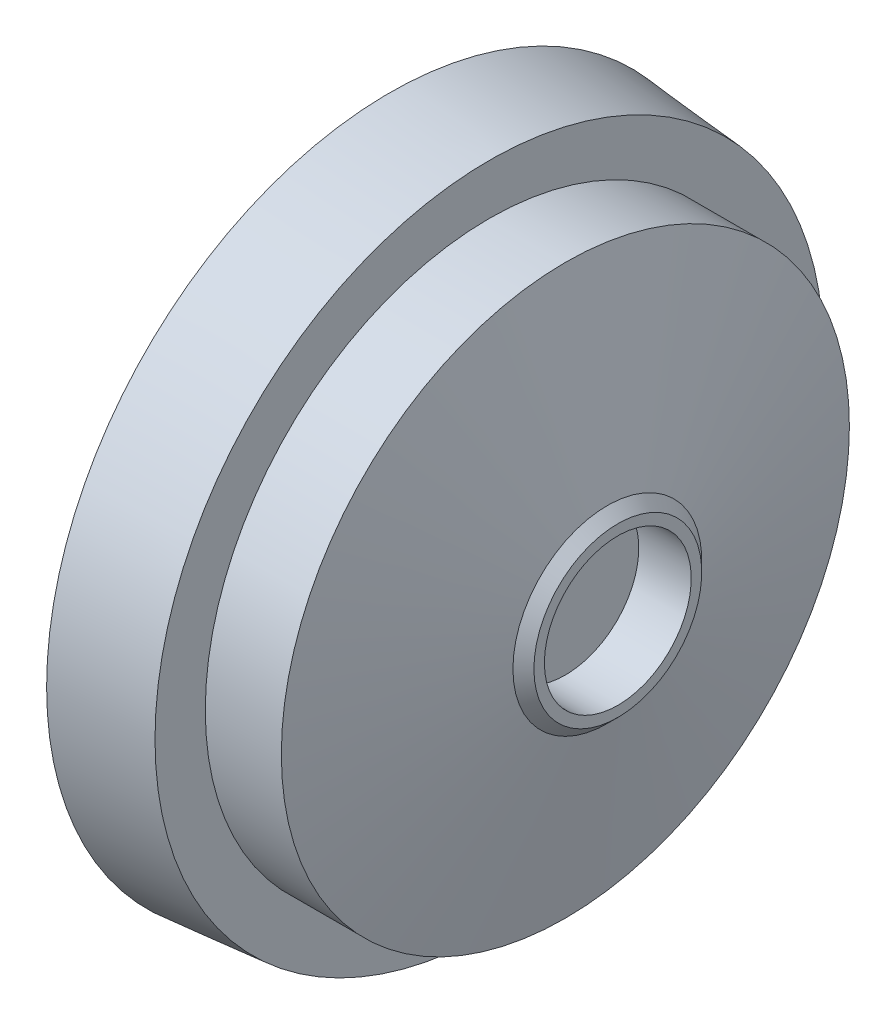
from build123d import *

# Parameters (mm, degrees)
FILLET1_R = 3


with BuildPart() as part:
    # Sketch1 → Revolve1 (revolve)
    with BuildSketch(Plane.XY):
        Polygon((0, 65.4), (19, 63.737715393), (19, 54.15), (33.5, 54.15), (41.5, 18), (43.5, 16), (43.5, 14), (33.5, 14), (33.5, 0), (0, 0), (-1.6, 0), (-1.6, 53.6), (10.4, 53.6), (10.4, 60.9), (0, 60.9), align=None)
    revolve(axis=Axis((0, 0, 0), (1, 0, 0)))

    # Fillet1
    fillet1_edges = [part.edges().sort_by_distance(p)[0] for p in [
        (-1.6, -53.6, 0),
    ]]
    fillet(fillet1_edges, radius=FILLET1_R)


solid = part.part
